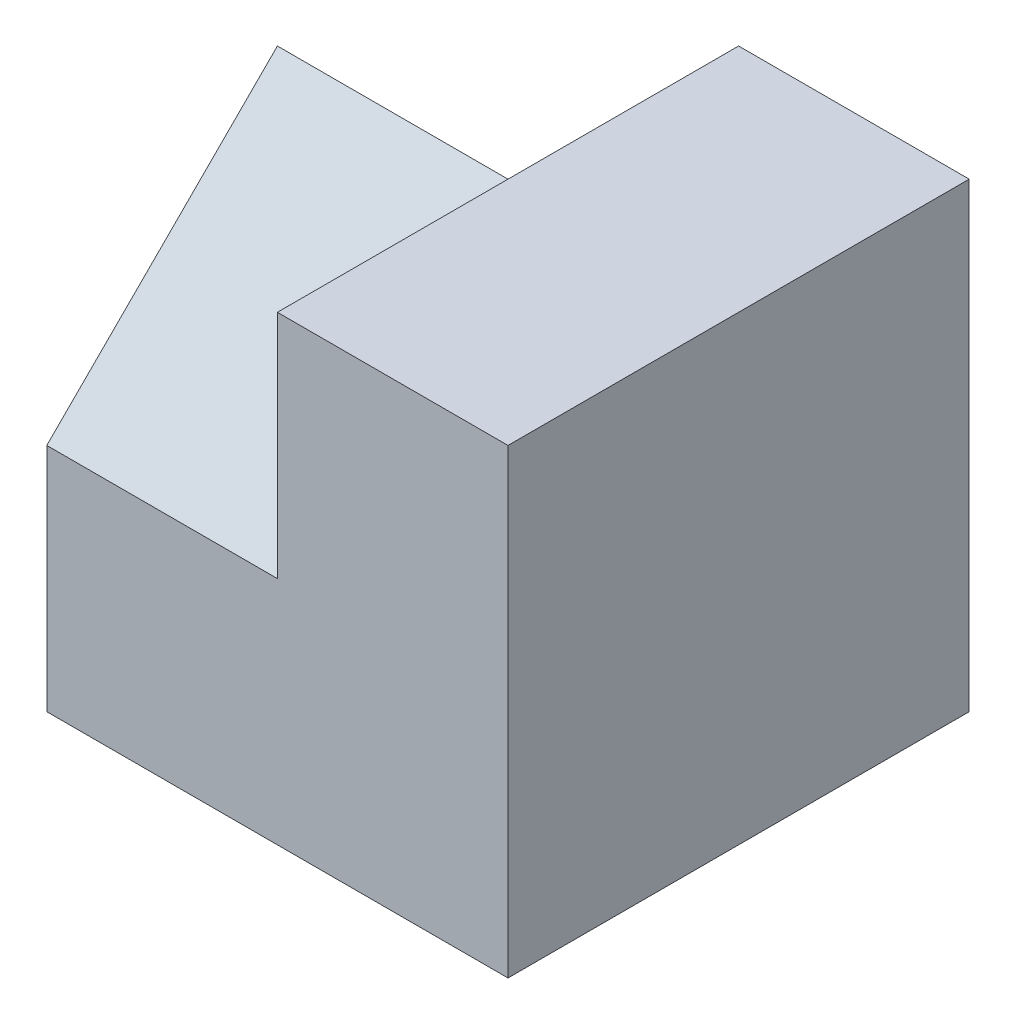
from build123d import *

# Parameters (mm, degrees)
SKETCH1_W           = 4
SKETCH1_H           = 4
BOSS_EXTRUDE1_DEPTH = 4
CUT_EXTRUDE1_DEPTH  = 2


with BuildPart() as part:
    # Sketch1 → Boss-Extrude1 (new body)
    with BuildSketch(Plane(origin=(0, 0, 0), x_dir=(1, 0, 0), z_dir=(0, 1, 0))):
        Rectangle(SKETCH1_W, SKETCH1_H)
    extrude(amount=BOSS_EXTRUDE1_DEPTH)

    # Sketch2 → Cut-Extrude1 (cut)
    with BuildSketch(Plane.ZY.offset(2)):
        Polygon((0, 4), (2, 2), (2, 4), align=None)
        Polygon((0, 0), (-2, 2), (-2, 0), align=None)
        Polygon((-2, 2), (0, 4), (-2, 4), align=None)
    extrude(amount=-CUT_EXTRUDE1_DEPTH, mode=Mode.SUBTRACT)


solid = part.part
